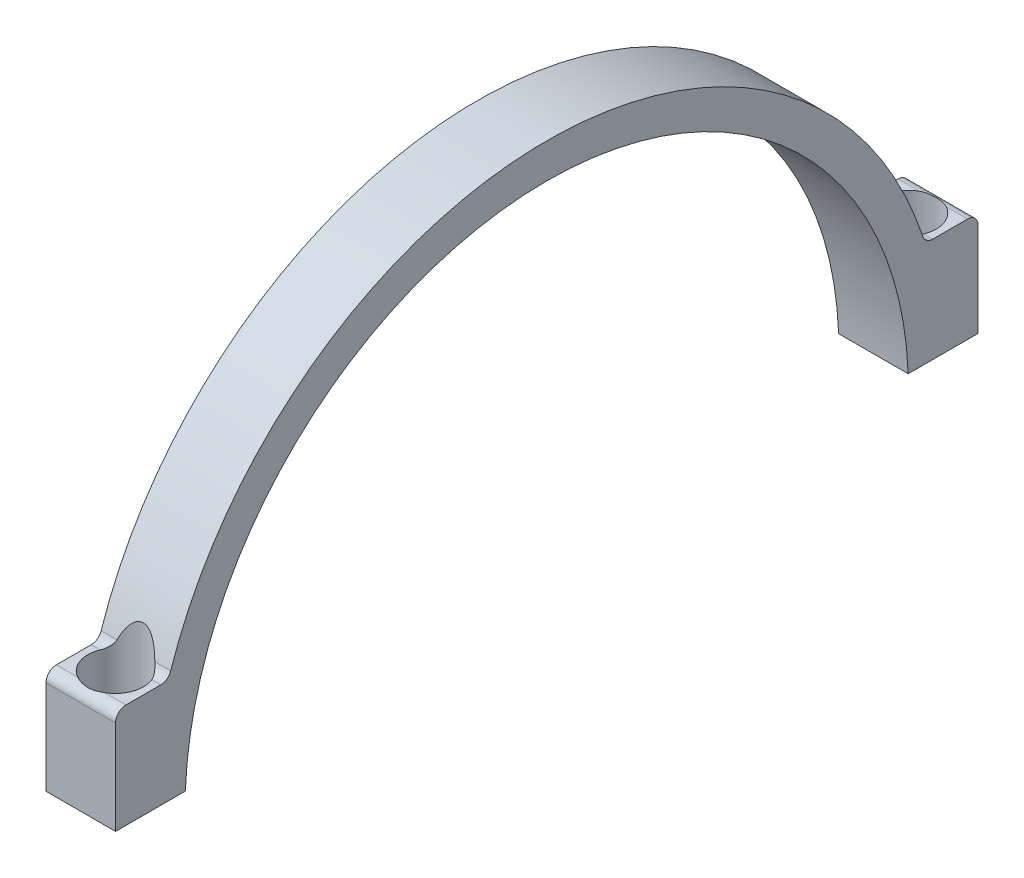
from build123d import *

# Parameters (mm, degrees)
BOSS_EXTRUDE1_DEPTH                        = 10
CBORE_FOR_M4_CHEESE_HEAD_SCREW1_AT_2_COUNT = 2
CBORE_FOR_M4_CHEESE_HEAD_SCREW1_AT_2_PITCH = 114
SKETCH6_R                                  = 4
CUT_EXTRUDE1_DEPTH                         = 8


with BuildPart() as part:
    # Sketch1 → Boss-Extrude1 (new body)
    with BuildSketch(Plane(origin=(0, 0, 0), x_dir=(0, 0, -1), z_dir=(1, 0, 0))):
        with BuildLine():
            Line((-62, 2), (-51.961524227, 2))
            ThreePointArc((-51.961524227, 2), (0, 52), (51.961524227, 2))
            Line((51.961524227, 2), (62, 2))
            Line((62, 2), (62, 15.5))
            ThreePointArc((62, 15.5), (61.560660172, 16.560660172), (60.5, 17))
            Line((60.5, 17), (55.497747702, 17))
            ThreePointArc((55.497747702, 17), (54.620689683, 17.283131383), (54.07472853, 18.025641026))
            ThreePointArc((54.07472853, 18.025641026), (0, 57), (-54.07472853, 18.025641026))
            ThreePointArc((-54.07472853, 18.025641026), (-54.620689683, 17.283131383), (-55.497747702, 17))
            Line((-55.497747702, 17), (-60.5, 17))
            ThreePointArc((-60.5, 17), (-61.560660172, 16.560660172), (-62, 15.5))
            Line((-62, 15.5), (-62, 2))
        make_face()
    extrude(amount=BOSS_EXTRUDE1_DEPTH)

    # Sketch4 → CBORE for M4 Cheese Head Screw1 (revolve, cut)
    with BuildSketch(Plane(origin=(5, 17, -57), x_dir=(0, 0, 1), z_dir=(1, 0, 0))):
        Polygon((0, 0), (0, 21.291850331), (2.15, 20), (2.15, 6.6), (4, 6.6), (4, 0), align=None)
    cbore_for_m4_cheese_head_screw1 = revolve(axis=Axis((5, 23.35, -57), (0, -1, 0)), mode=Mode.SUBTRACT)

    # CBORE for M4 Cheese Head Screw1 at 2: CBORE for M4 Cheese Head Screw1 ×2
    with Locations(*[(0, 0, i * CBORE_FOR_M4_CHEESE_HEAD_SCREW1_AT_2_PITCH) for i in range(1, CBORE_FOR_M4_CHEESE_HEAD_SCREW1_AT_2_COUNT)]):
        add(cbore_for_m4_cheese_head_screw1, mode=Mode.SUBTRACT)

    # Sketch6 → Cut-Extrude1 (cut)
    with BuildSketch(Plane(origin=(0, 17, 0), x_dir=(1, 0, 0), z_dir=(0, 1, 0))):
        with Locations((5, 57)):
            Circle(SKETCH6_R)
        with Locations((5, -57)):
            Circle(SKETCH6_R)
    extrude(amount=CUT_EXTRUDE1_DEPTH, mode=Mode.SUBTRACT)


solid = part.part
